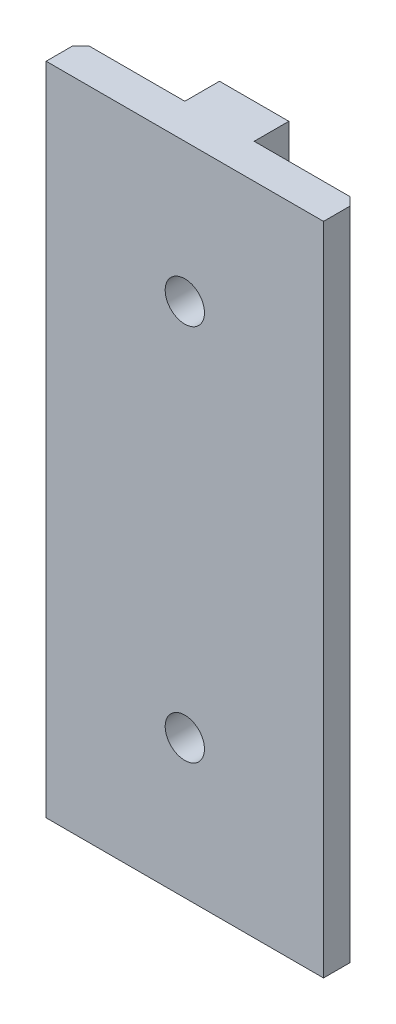
from build123d import *

# Parameters (mm, degrees)
BOSS_EXTRUDE1_DEPTH          = 60
SKETCH2_R                    = 1.5
CUT_EXTRUDE2_DEPTH           = 7.35
CSK_FOR_M3_SFHCS1_AT_2_COUNT = 2
CSK_FOR_M3_SFHCS1_AT_2_PITCH = 34.6
CHAMFER1_SIZE                = 0.762


with BuildPart() as part:
    # Sketch1 → Boss-Extrude1 (new body)
    with BuildSketch(Plane(origin=(0, 0, 0), x_dir=(1, 0, 0), z_dir=(0, 1, 0))):
        Polygon((-3.175, 6.35), (3.175, 6.35), (3.175, 3.175), (12.7, 3.175), (12.7, 0), (-12.7, 0), (-12.7, 3.175), (-3.175, 3.175), align=None)
    extrude(amount=BOSS_EXTRUDE1_DEPTH)

    # Sketch2 → Cut-Extrude2 (cut, through all)
    with BuildSketch(Plane(origin=(0, 0, -6.35), x_dir=(-1, 0, 0), z_dir=(0, 0, -1))):
        with Locations((0, 47.3)):
            Circle(SKETCH2_R)
        with Locations((0, 12.7)):
            Circle(SKETCH2_R)
    extrude(amount=-CUT_EXTRUDE2_DEPTH, mode=Mode.SUBTRACT)

    # Sketch4 → CSK for M3 SFHCS1 (revolve, cut)
    with BuildSketch(Plane(origin=(0, 12.7, -6.35), x_dir=(0, 1, 0), z_dir=(1, 0, 0))):
        Polygon((0, 0), (0, 6.35), (1.8, 6.35), (1.8, 2.83), (3.36, 1.27), (3.36, 0), align=None)
    csk_for_m3_sfhcs1 = revolve(axis=Axis((0, 12.7, -12.7), (0, 0, 1)), mode=Mode.SUBTRACT)

    # CSK for M3 SFHCS1 at 2: CSK for M3 SFHCS1 ×2
    with Locations(*[(0, i * CSK_FOR_M3_SFHCS1_AT_2_PITCH, 0) for i in range(1, CSK_FOR_M3_SFHCS1_AT_2_COUNT)]):
        add(csk_for_m3_sfhcs1, mode=Mode.SUBTRACT)

    # Chamfer1
    chamfer1_edges = [part.edges().sort_by_distance(p)[0] for p in [
        (12.7, 30, -3.175),
        (-12.7, 30, -3.175),
    ]]
    chamfer(chamfer1_edges, length=CHAMFER1_SIZE)


solid = part.part
